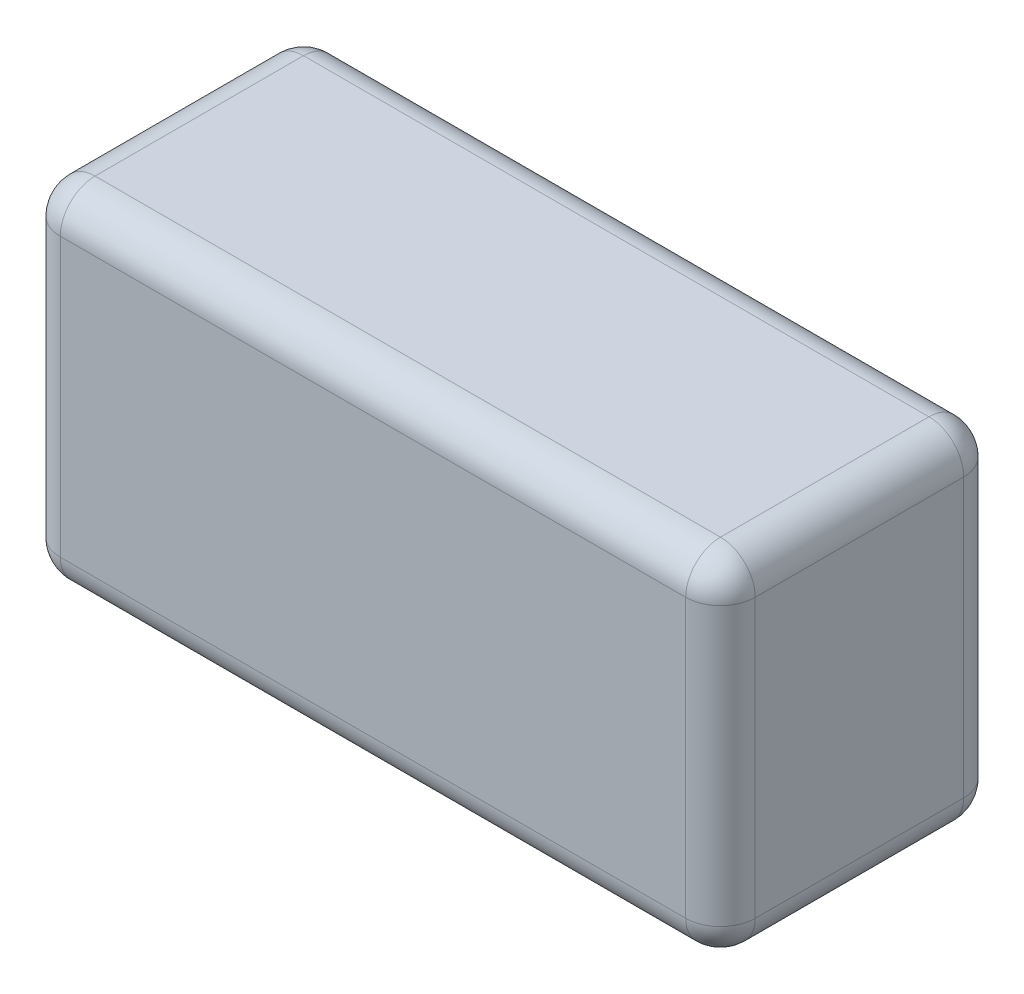
from build123d import *

# Parameters (mm, degrees)
SKETCH1_W           = 63.5
SKETCH1_H           = 31.75
BOSS_EXTRUDE1_DEPTH = 25.4
FILLET1_R           = 3.175


with BuildPart() as part:
    # Sketch1 → Boss-Extrude1 (new body)
    with BuildSketch(Plane.XY):
        Rectangle(SKETCH1_W, SKETCH1_H)
    extrude(amount=BOSS_EXTRUDE1_DEPTH)

    # Fillet1
    fillet1_edges = [part.edges().sort_by_distance(p)[0] for p in [
        (-31.75, 0, 25.4),
        (0, -15.875, 25.4),
        (31.75, 0, 25.4),
        (0, -15.875, 0),
        (-31.75, 0, 0),
        (0, 15.875, 0),
        (31.75, 0, 0),
        (0, 15.875, 25.4),
        (31.75, -15.875, 12.7),
        (-31.75, -15.875, 12.7),
        (-31.75, 15.875, 12.7),
        (31.75, 15.875, 12.7),
    ]]
    fillet(fillet1_edges, radius=FILLET1_R)


solid = part.part
